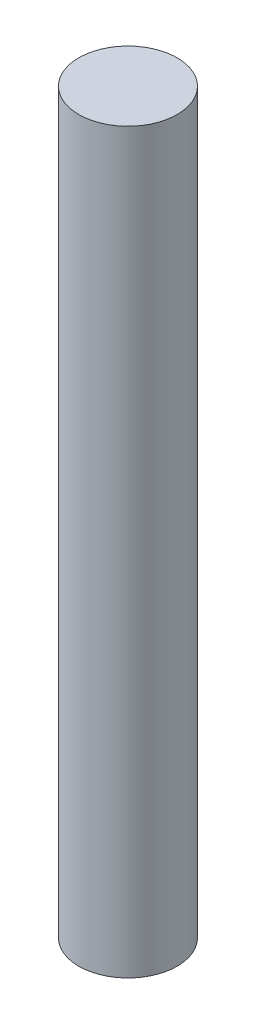
from build123d import *

# Parameters (mm, degrees)
SKETCH1_R           = 6.35
BOSS_EXTRUDE1_DEPTH = 95.25


with BuildPart() as part:
    # Sketch1 → Boss-Extrude1 (new body)
    with BuildSketch(Plane(origin=(0, 0, 0), x_dir=(1, 0, 0), z_dir=(0, 1, 0))):
        Circle(SKETCH1_R)
    extrude(amount=BOSS_EXTRUDE1_DEPTH)


solid = part.part
